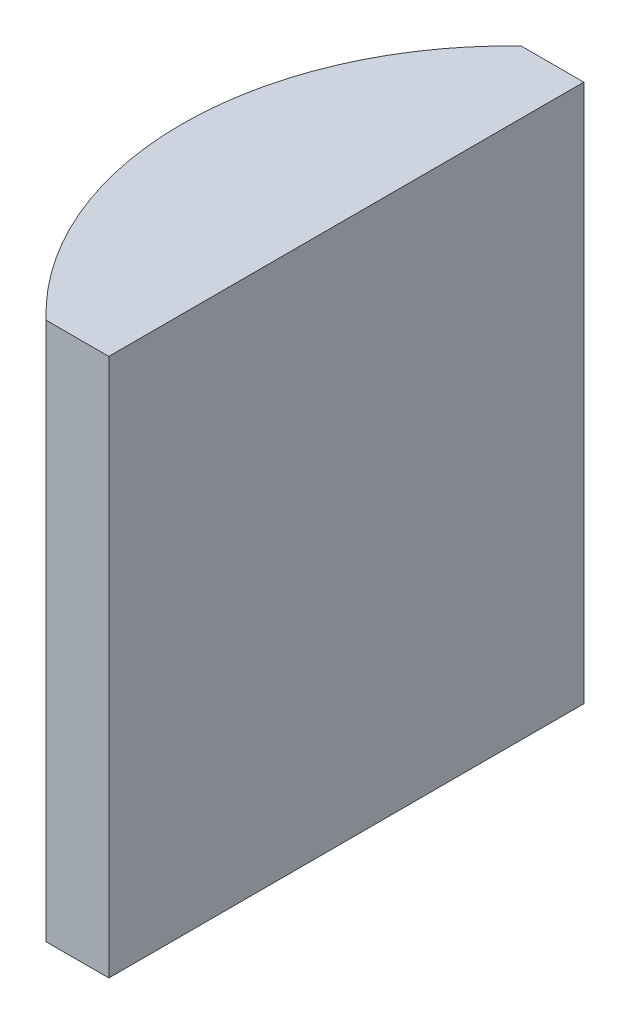
from build123d import *

# Parameters (mm, degrees)
EXTRUDE_1_DEPTH = 17


with BuildPart() as part:
    # 草图1 → 凸台-拉伸1 (new body)
    with BuildSketch(Plane(origin=(0, 0, 0), x_dir=(1, 0, 0), z_dir=(0, 1, 0))):
        with BuildLine():
            Line((-2.762772906, 7.5), (-0.784795665, 7.5))
            Line((-0.784795665, 7.5), (-0.784795665, -7.5))
            Line((-0.784795665, -7.5), (-2.762772906, -7.5))
            ThreePointArc((-2.762772906, -7.5), (-5.984795665, 0), (-2.762772906, 7.5))
        make_face()
    extrude(amount=EXTRUDE_1_DEPTH)


solid = part.part
